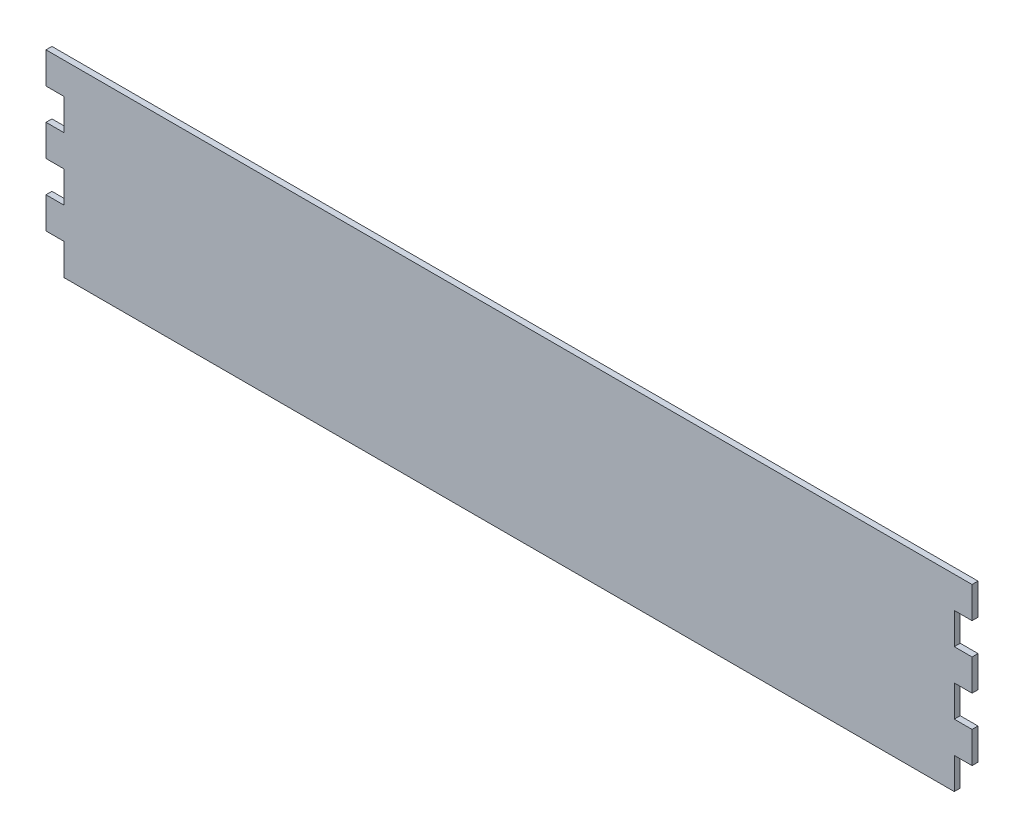
from build123d import *

# Parameters (mm, degrees)
BOSS_EXTRU_1_DEPTH = 2


with BuildPart() as part:
    # Esquisse1 → Boss.-Extru.1 (new body)
    with BuildSketch(Plane.XY):
        Polygon((-63.997372642, -108.680130338), (236.002627358, -108.680130338), (236.002627358, -98.108701767), (242.002627358, -98.108701767), (242.002627358, -87.537273195), (236.002627358, -87.537273195), (236.002627358, -76.965844624), (242.002627358, -76.965844624), (242.002627358, -66.394416052), (236.002627358, -66.394416052), (236.002627358, -55.822987481), (242.002627358, -55.822987481), (242.002627358, -45.25155891), (-69.997372642, -45.25155891), (-69.997372642, -55.822987481), (-63.997372642, -55.822987481), (-63.997372642, -66.394416052), (-69.997372642, -66.394416052), (-69.997372642, -76.965844624), (-63.997372642, -76.965844624), (-63.997372642, -87.537273195), (-69.997372642, -87.537273195), (-69.997372642, -98.108701767), (-63.997372642, -98.108701767), align=None)
    extrude(amount=-BOSS_EXTRU_1_DEPTH)


solid = part.part
